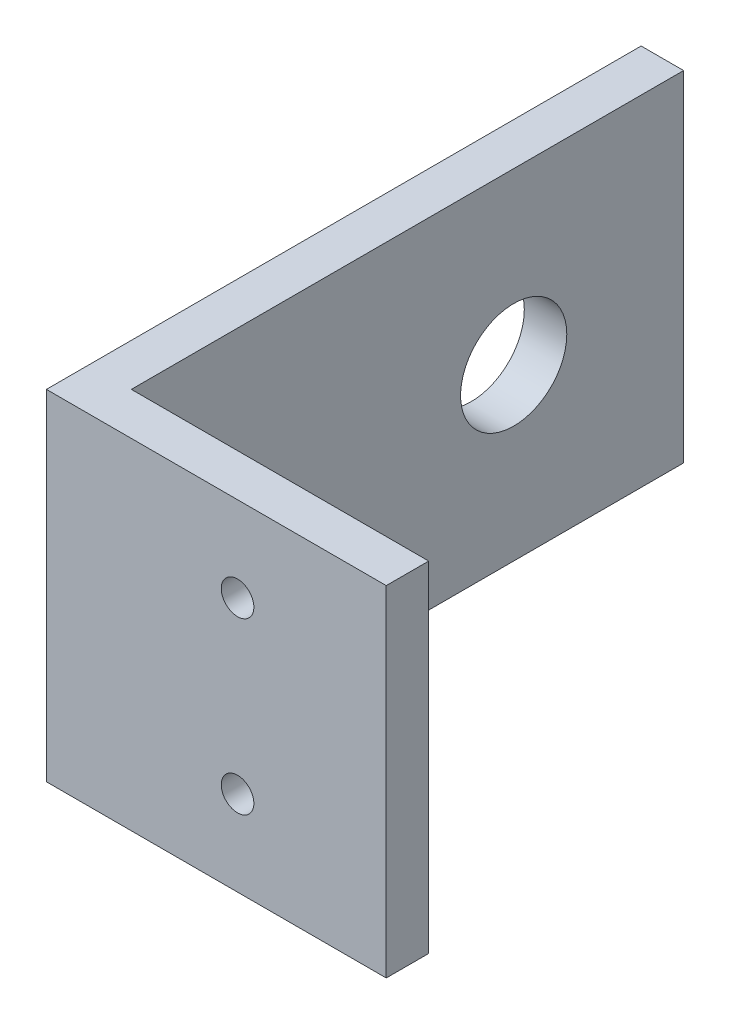
from build123d import *

# Parameters (mm, degrees)
BOSS_EXTRUDE1_DEPTH                            = 25.4
SKETCH2_R                                      = 3.96875
CUT_EXTRUDE1_DEPTH                             = 4.175
CSK_FOR_2_FLAT_HEAD_MACHINE_SCREW1_D           = 2.4384
CSK_FOR_2_FLAT_HEAD_MACHINE_SCREW1_CSINK_D     = 4.3688
CSK_FOR_2_FLAT_HEAD_MACHINE_SCREW1_CSINK_ANGLE = 82


with BuildPart() as part:
    # Sketch1 → Boss-Extrude1 (new body)
    with BuildSketch(Plane(origin=(0, 0, 0), x_dir=(1, 0, 0), z_dir=(0, 1, 0))):
        Polygon((0, 0), (0, 44.45), (3.175, 44.45), (3.175, 3.175), (25.4, 3.175), (25.4, 0), align=None)
    extrude(amount=BOSS_EXTRUDE1_DEPTH)

    # Sketch2 → Cut-Extrude1 (cut, through all)
    with BuildSketch(Plane(origin=(3.175, 0, 0), x_dir=(0, 0, -1), z_dir=(1, 0, 0))):
        with Locations((31.75, 12.7)):
            Circle(SKETCH2_R)
    extrude(amount=-CUT_EXTRUDE1_DEPTH, mode=Mode.SUBTRACT)

    # CSK for #2 Flat Head Machine Screw1 (through all)
    with Locations(Plane(origin=(0, 0, -3.175), x_dir=(-1, 0, 0), z_dir=(0, 0, -1))):
        with Locations((-14.2875, 19.05), (-14.2875, 6.35)):
            CounterSinkHole(CSK_FOR_2_FLAT_HEAD_MACHINE_SCREW1_D / 2, CSK_FOR_2_FLAT_HEAD_MACHINE_SCREW1_CSINK_D / 2, counter_sink_angle=CSK_FOR_2_FLAT_HEAD_MACHINE_SCREW1_CSINK_ANGLE)


solid = part.part
